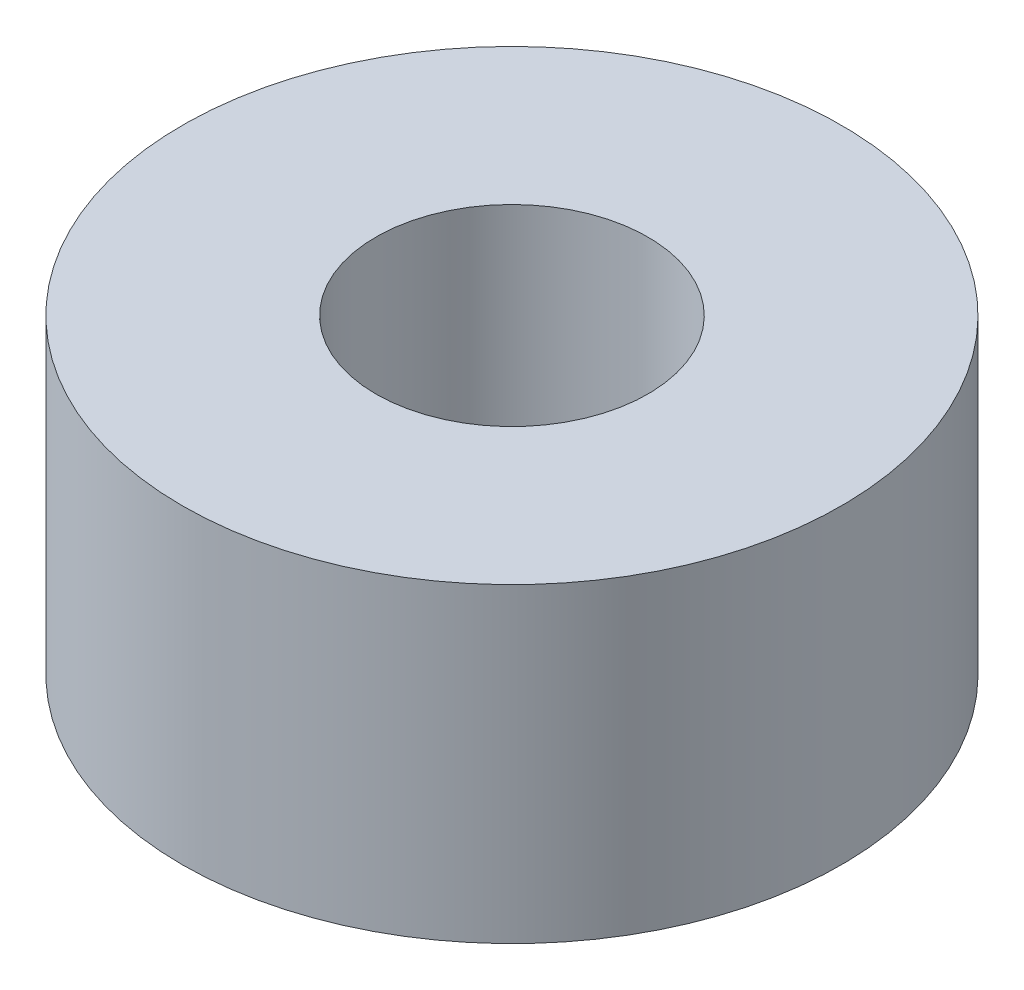
from build123d import *

# Parameters (mm, degrees)
SKETCH1_R           = 13.462
SKETCH1_R_2         = 5.55625
BOSS_EXTRUDE1_DEPTH = 12.7


with BuildPart() as part:
    # Sketch1 → Boss-Extrude1 (new body)
    with BuildSketch(Plane(origin=(0, 0, 0), x_dir=(1, 0, 0), z_dir=(0, 1, 0))):
        Circle(SKETCH1_R)
        Circle(SKETCH1_R_2, mode=Mode.SUBTRACT)
    extrude(amount=BOSS_EXTRUDE1_DEPTH)


solid = part.part
